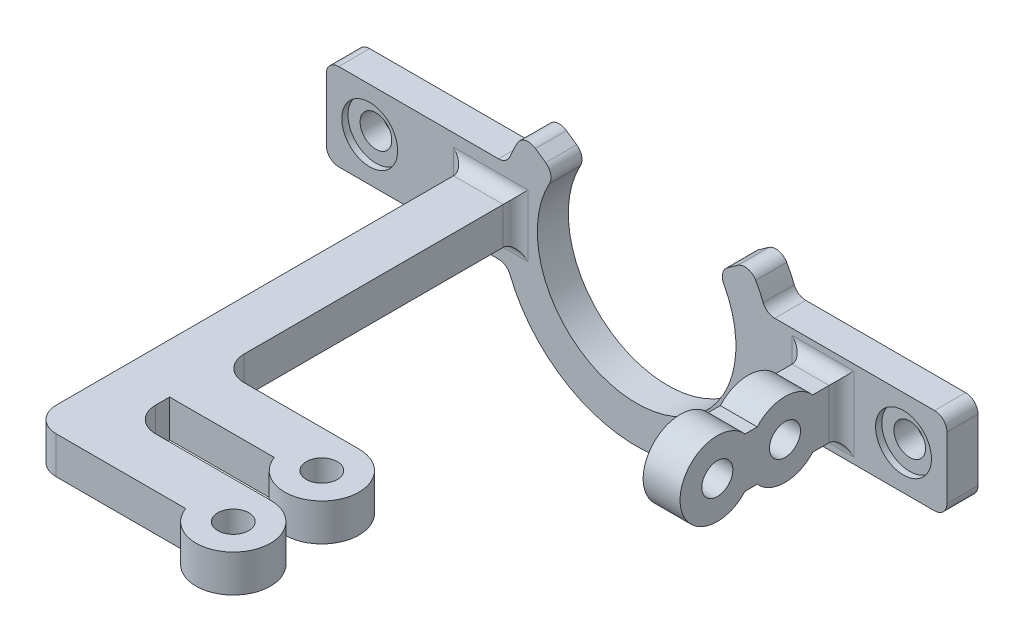
from build123d import *

# Parameters (mm, degrees)
SKETCH1_R                = 2.55
BOSS_EXTRUDE1_DEPTH      = 5
SKETCH4_R                = 4.5
CUT_EXTRUDE2_DEPTH       = 1
SKETCH6_W                = 5.947651005
SKETCH6_H                = 20
BOSS_EXTRUDE2_DEPTH      = 4
BOSS_EXTRUDE2_DEPTH_BACK = 4
SKETCH11_R               = 4.5
CUT_EXTRUDE3_DEPTH       = 0.5
SKETCH16_R               = 2.5
BOSS_EXTRUDE3_DEPTH      = 3
BOSS_EXTRUDE3_DEPTH_BACK = 3
FILLET3_R                = 2
BOSS_EXTRUDE4_DEPTH      = 5.947651
CUT_EXTRUDE5_REACH       = 85
SKETCH18_R               = 2.5


with BuildPart() as part:
    # Sketch1 → Boss-Extrude1 (new body)
    with BuildSketch(Plane.XY):
        with BuildLine():
            Line((100, 25), (100, 20))
            ThreePointArc((100, 20), (99.414213562, 18.585786438), (98, 18))
            Line((98, 18), (72.248595461, 18))
            ThreePointArc((72.248595461, 18), (71.130561473, 17.658312395), (70.39454584, 16.75))
            ThreePointArc((70.39454584, 16.75), (50, 3), (29.60545416, 16.75))
            ThreePointArc((29.60545416, 16.75), (28.869438527, 17.658312395), (27.751404539, 18))
            Line((27.751404539, 18), (2, 18))
            ThreePointArc((2, 18), (0.585786438, 18.585786438), (0, 20))
            Line((0, 20), (0, 25))
            Line((0, 25), (0, 30))
            ThreePointArc((0, 30), (0.585786438, 31.414213562), (2, 32))
            Line((2, 32), (21.056240945, 32))
            Line((21.056240945, 32), (27.751404539, 32))
            ThreePointArc((27.751404539, 32), (28.869438527, 32.341687605), (29.60545416, 33.25))
            ThreePointArc((29.60545416, 33.25), (30.166752838, 34.520625347), (30.807119991, 35.753295167))
            ThreePointArc((30.807119991, 35.753295167), (32.106461975, 36.725482012), (33.699080137, 36.414026968))
            Line((33.699080137, 36.414026968), (35.34656276, 35.260447216))
            ThreePointArc((35.34656276, 35.260447216), (36.146649881, 34.078494315), (35.955031011, 32.664127224))
            ThreePointArc((35.955031011, 32.664127224), (50, 9), (64.044968989, 32.664127224))
            ThreePointArc((64.044968989, 32.664127224), (63.853350119, 34.078494315), (64.65343724, 35.260447216))
            Line((64.65343724, 35.260447216), (66.300919863, 36.414026968))
            ThreePointArc((66.300919863, 36.414026968), (67.893538025, 36.725482012), (69.192880009, 35.753295167))
            ThreePointArc((69.192880009, 35.753295167), (69.833247162, 34.520625347), (70.39454584, 33.25))
            ThreePointArc((70.39454584, 33.25), (71.130561473, 32.341687605), (72.248595461, 32))
            Line((72.248595461, 32), (78.943759055, 32))
            Line((78.943759055, 32), (98, 32))
            ThreePointArc((98, 32), (99.414213562, 31.414213562), (100, 30))
            Line((100, 30), (100, 25))
        make_face()
        with Locations((93, 25)):
            Circle(SKETCH1_R, mode=Mode.SUBTRACT)
        with Locations((7, 25)):
            Circle(SKETCH1_R, mode=Mode.SUBTRACT)
    extrude(amount=BOSS_EXTRUDE1_DEPTH)

    # Sketch4 → Cut-Extrude2 (cut)
    with BuildSketch(Plane.XY.offset(5)):
        with Locations((93, 25)):
            Circle(SKETCH4_R)
        with Locations((7, 25)):
            Circle(SKETCH4_R)
    extrude(amount=-CUT_EXTRUDE2_DEPTH, mode=Mode.SUBTRACT)

    # Sketch6 → Boss-Extrude2 (add, two sides)
    with BuildSketch(Plane(origin=(0, 25, 0), x_dir=(-1, 0, 0), z_dir=(0, -1, 0))) as boss_extrude2_sk:
        with Locations((-80.026174497, -15)):
            Rectangle(SKETCH6_W, SKETCH6_H)
    extrude(amount=BOSS_EXTRUDE2_DEPTH)
    extrude(boss_extrude2_sk.sketch, amount=-BOSS_EXTRUDE2_DEPTH_BACK)

    # Sketch11 → Cut-Extrude3 (cut)
    with BuildSketch(Plane(origin=(0, 0, 0), x_dir=(-1, 0, 0), z_dir=(0, 0, -1))):
        with Locations((-93, 25)):
            Circle(SKETCH11_R)
        with Locations((-7, 25)):
            Circle(SKETCH11_R)
    extrude(amount=-CUT_EXTRUDE3_DEPTH, mode=Mode.SUBTRACT)

    # Sketch16 → Boss-Extrude3 (add, two sides)
    with BuildSketch(Plane(origin=(0, 25, 0), x_dir=(-1, 0, 0), z_dir=(0, -1, 0))) as boss_extrude3_sk:
        with BuildLine():
            Line((-30.494270905, -5), (-22.494270905, -5))
            Line((-22.494270905, -5), (-22.494270905, -71))
            ThreePointArc((-22.494270905, -71), (-23.665843781, -73.828427125), (-26.494270905, -75))
            Line((-26.494270905, -75), (-30.494270905, -75))
            Line((-30.494270905, -75), (-47.361403242, -75))
            ThreePointArc((-47.361403242, -75), (-57.917236977, -76.464101615), (-53.018257491, -67))
            Line((-53.018257491, -67), (-34.494270905, -67))
            ThreePointArc((-34.494270905, -67), (-31.665843781, -65.828427125), (-30.494270905, -63))
            Line((-30.494270905, -63), (-30.494270905, -60.732138804))
            Line((-30.494270905, -60.732138804), (-47.361403242, -60.732138804))
            ThreePointArc((-47.361403242, -60.732138804), (-57.917236977, -62.196240419), (-53.018257491, -52.732138804))
            Line((-53.018257491, -52.732138804), (-34.494270905, -52.732138804))
            ThreePointArc((-34.494270905, -52.732138804), (-31.665843781, -51.560565928), (-30.494270905, -48.732138804))
            Line((-30.494270905, -48.732138804), (-30.494270905, -5))
        make_face()
        with Locations((-53.018257491, -73)):
            Circle(SKETCH16_R, mode=Mode.SUBTRACT)
        with Locations((-53.018257491, -58.732138804)):
            Circle(SKETCH16_R, mode=Mode.SUBTRACT)
    extrude(amount=BOSS_EXTRUDE3_DEPTH)
    extrude(boss_extrude3_sk.sketch, amount=-BOSS_EXTRUDE3_DEPTH_BACK)

    # Fillet3
    fillet3_edges = [part.edges().sort_by_distance(p)[0] for p in [
        (83, 25, 5),
        (80.026174498, 29, 5),
        (77.052348995, 25, 5),
        (80.026174498, 21, 5),
        (30.494270905, 25, 5),
        (26.494270905, 28, 5),
        (22.494270905, 25, 5),
        (26.494270905, 22, 5),
    ]]
    fillet(fillet3_edges, radius=FILLET3_R)

    # Sketch17 → Boss-Extrude4 (add)
    with BuildSketch(Plane(origin=(83, 0, 0), x_dir=(0, 0, -1), z_dir=(1, 0, 0))):
        with BuildLine():
            ThreePointArc((-19.547210182, 27.503414308), (-31, 25), (-19.547210182, 22.496585692))
            ThreePointArc((-19.547210182, 22.496585692), (-8.094420363, 25), (-19.547210182, 27.503414308))
        make_face()
    extrude(amount=-BOSS_EXTRUDE4_DEPTH)

    # Sketch18 → Cut-Extrude5 (cut, up to next)
    with BuildSketch(Plane(origin=(83, 0, 0), x_dir=(0, 0, -1), z_dir=(1, 0, 0)), mode=Mode.PRIVATE) as cut_extrude5_sk1:
        with Locations((-25, 25)):
            Circle(SKETCH18_R)
    cut_extrude5_tool1 = extrude(cut_extrude5_sk1.sketch, amount=-CUT_EXTRUDE5_REACH, mode=Mode.PRIVATE) & part.part
    add(cut_extrude5_tool1.solids().sort_by_distance((83, 25, 25))[0], mode=Mode.SUBTRACT)
    # Sketch18 → Cut-Extrude5 (cut, up to next)
    with BuildSketch(Plane(origin=(83, 0, 0), x_dir=(0, 0, -1), z_dir=(1, 0, 0)), mode=Mode.PRIVATE) as cut_extrude5_sk2:
        with Locations((-14.094420363, 25)):
            Circle(SKETCH18_R)
    cut_extrude5_tool2 = extrude(cut_extrude5_sk2.sketch, amount=-CUT_EXTRUDE5_REACH, mode=Mode.PRIVATE) & part.part
    add(cut_extrude5_tool2.solids().sort_by_distance((83, 25, 14.09442))[0], mode=Mode.SUBTRACT)


solid = part.part
